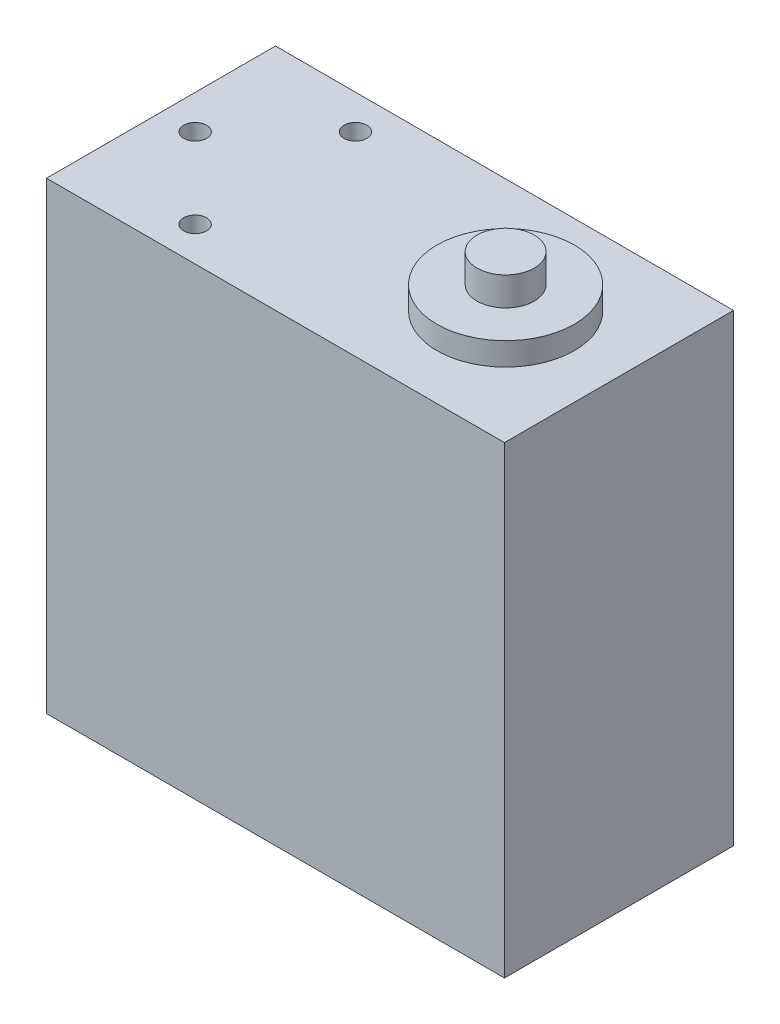
from build123d import *

# Parameters (mm, degrees)
SKETCH_1_W          = 40
SKETCH_1_H          = 40.5
EXTRUDE_1_DEPTH     = 20
SKETCH_2_R          = 6
EXTRUDE_2_DEPTH     = 2
SKETCH_4_R          = 2.5
EXTRUDE_3_DEPTH     = 2.5
SKETCH_5_R          = 2.5
EXTRUDE_4_DEPTH     = 2.5
SKETCH_6_R          = 1
CUT_EXTRUDE_1_DEPTH = 2.5
SKETCH_7_R          = 1
CUT_EXTRUDE_2_DEPTH = 2.5


with BuildPart() as part:
    # 草图1 → 凸台-拉伸1 (new body)
    with BuildSketch(Plane.XY):
        with Locations((20, 20.25)):
            Rectangle(SKETCH_1_W, SKETCH_1_H)
    extrude(amount=EXTRUDE_1_DEPTH)

    # 草图2 → 凸台-拉伸2 (add)
    with BuildSketch(Plane(origin=(0, 40.5, 0), x_dir=(1, 0, 0), z_dir=(0, 1, 0))):
        with Locations((30.1, -10)):
            Circle(SKETCH_2_R)
    extrude_2 = extrude(amount=EXTRUDE_2_DEPTH)

    # 镜向1: 凸台-拉伸2 across plane
    add(extrude_2.mirror(Plane.ZX.offset(20.25)))

    # 草图4 → 凸台-拉伸3 (add)
    with BuildSketch(Plane(origin=(0, 42.5, 0), x_dir=(1, 0, 0), z_dir=(0, 1, 0))):
        with Locations((30.1, -10)):
            Circle(SKETCH_4_R)
    extrude(amount=EXTRUDE_3_DEPTH)

    # 草图5 → 凸台-拉伸4 (add)
    with BuildSketch(Plane.XZ.offset(2)):
        with Locations((30.1, 10)):
            Circle(SKETCH_5_R)
    extrude(amount=EXTRUDE_4_DEPTH)

    # 草图6 → 切除-拉伸1 (cut)
    with BuildSketch(Plane(origin=(0, 40.5, 0), x_dir=(1, 0, 0), z_dir=(0, 1, 0))):
        with Locations((9.98, -3)):
            Circle(SKETCH_6_R)
        with Locations((9.98, -17)):
            Circle(SKETCH_6_R)
        with Locations((2.98, -10)):
            Circle(SKETCH_6_R)
    extrude(amount=-CUT_EXTRUDE_1_DEPTH, mode=Mode.SUBTRACT)

    # 草图7 → 切除-拉伸2 (cut)
    with BuildSketch(Plane.XZ):
        with Locations((2.5, 17.5)):
            Circle(SKETCH_7_R)
        with Locations((17.5, 17.5)):
            Circle(SKETCH_7_R)
        with Locations((17.5, 2.5)):
            Circle(SKETCH_7_R)
        with Locations((2.5, 2.5)):
            Circle(SKETCH_7_R)
    extrude(amount=-CUT_EXTRUDE_2_DEPTH, mode=Mode.SUBTRACT)


solid = part.part
